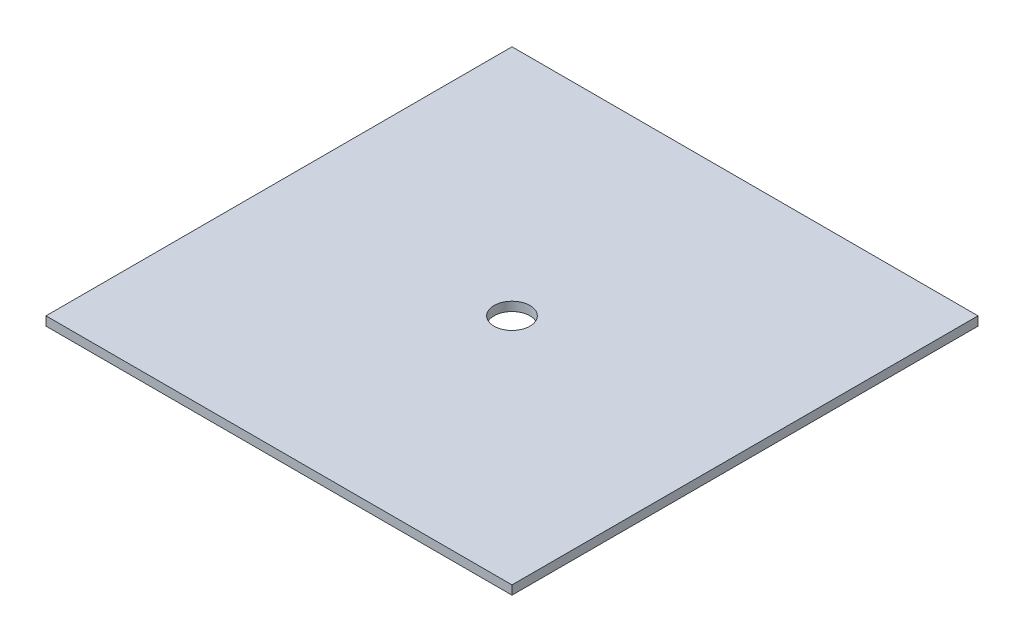
from build123d import *

# Parameters (mm, degrees)
SKETCH1_W       = 13
SKETCH1_H       = 13
MESH_DEPTH      = 0.25
HOLE_DEPTH      = 10
HOLE_DEPTH_BACK = 10
SKETCH2_R       = 0.5


with BuildPart() as part:
    # Sketch1 → Mesh (new body)
    with BuildSketch(Plane(origin=(0, 0, 0), x_dir=(1, 0, 0), z_dir=(0, 1, 0))):
        Rectangle(SKETCH1_W, SKETCH1_H)
    extrude(amount=MESH_DEPTH)

    # Sketch2 → Hole (cut, two sides: drawn at the far end of the back side and taken through both)
    with BuildSketch(Plane(origin=(0, 0.25, 0), x_dir=(1, 0, 0), z_dir=(0, 1, 0)).offset(-HOLE_DEPTH_BACK)):
        Circle(SKETCH2_R)
    extrude(amount=HOLE_DEPTH + HOLE_DEPTH_BACK, mode=Mode.SUBTRACT)


solid = part.part
